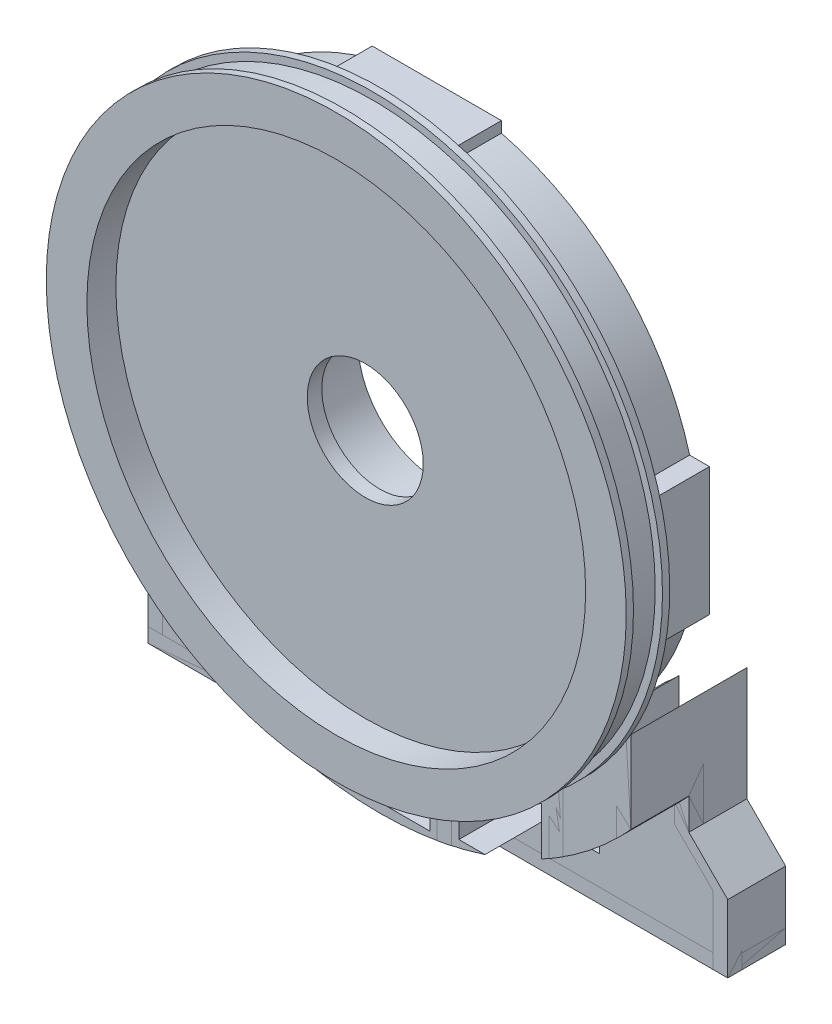
from build123d import *
from build123d.topology import SkipClean

# Parameters (mm, degrees)
SKETCH1_R                 = 200
BOSS_EXTRUDE1_DEPTH       = 5
SKETCH2_R                 = 195
BOSS_EXTRUDE2_DEPTH       = 10
SKETCH4_R                 = 180
SKETCH4_R_2               = 172
BOSS_EXTRUDE3_DEPTH       = 40
CUT_EXTRUDE1_DEPTH        = 286.657137142
CUT_EXTRUDE1_DEPTH_BACK   = 286.657137142
SKETCH6_R                 = 40
SKETCH7_R                 = 172
CUT_EXTRUDE2_DEPTH        = 20
BOSS_EXTRUDE12_DEPTH      = 40
CIRPATTERN7_COUNT         = 12
SKETCH5_R                 = 104.5
SKETCH5_R_2               = 96.5
BOSS_EXTRUDE14_DEPTH      = 40
SKETCH16_R                = 63
SKETCH16_R_2              = 55
BOSS_EXTRUDE15_DEPTH      = 40
CUT_EXTRUDE9_START        = -40
SKETCH18_R                = 55
CUT_EXTRUDE9_DEPTH        = 40
CUT_EXTRUDE13_DEPTH       = 40
BOSS_EXTRUDE18_START      = -40
SKETCH25_W                = 60.032294261
SKETCH25_H                = 45.012979572
BOSS_EXTRUDE18_DEPTH      = 40
SKETCH27_W                = 60.032294261
SKETCH27_H                = 45.012979572
SKETCH27_H_2              = 26.987020428
CUT_EXTRUDE15_DEPTH       = 40
CUT_EXTRUDE16_START       = -35
CUT_EXTRUDE16_DEPTH       = 35
BOSS_EXTRUDE19_START      = -44
SKETCH31_W                = 5.866847787
SKETCH31_H                = 9.437366397
SKETCH31_W_2              = 76.032294261
SKETCH31_W_3              = 7.195155409
BOSS_EXTRUDE19_DEPTH      = 44
BOSS_EXTRUDE20_DEPTH      = 80
BOSS_EXTRUDE21_DEPTH      = 80
BOSS_EXTRUDE21_2_DEPTH    = 80
BOSS_EXTRUDE26_DEPTH      = 50
CUT_EXTRUDE17_DEPTH       = 40
SKETCH41_W                = 400
SKETCH41_H                = 137.842811608
CUT_EXTRUDE18_DEPTH       = 452.7492864
BOSS_EXTRUDE29_DEPTH      = 40
BOSS_EXTRUDE29_DEPTH_BACK = 10
SKETCH42_W                = 400
SKETCH42_H                = 10
BOSS_EXTRUDE31_DEPTH      = 40
CUT_EXTRUDE19_DEPTH       = 332.517722
CUT_EXTRUDE20_DEPTH       = 10


with BuildPart() as part:
    # Sketch1 → Boss-Extrude1 (new body)
    with BuildSketch(Plane.XY):
        Circle(SKETCH1_R)
    boss_extrude1 = extrude(amount=BOSS_EXTRUDE1_DEPTH)

    # Sketch2 → Boss-Extrude2 (add)
    with BuildSketch(Plane.XY.offset(5)):
        Circle(SKETCH2_R)
    boss_extrude2 = extrude(amount=BOSS_EXTRUDE2_DEPTH)

    # Mirror2: Boss-Extrude2 across plane
    add(boss_extrude2.mirror(Plane.XY.offset(15)))

    # Mirror3: Boss-Extrude1 across plane
    add(boss_extrude1.mirror(Plane.XY.offset(15)))

    # Sketch4 → Boss-Extrude3 (add)
    with BuildSketch(Plane.XY):
        Circle(SKETCH4_R)
        Circle(SKETCH4_R_2, mode=Mode.SUBTRACT)
    extrude(amount=-BOSS_EXTRUDE3_DEPTH)

    # Sketch6 → Cut-Extrude1 (cut, two sides: drawn at the far end of the back side and taken through both)
    with BuildSketch(Plane(origin=(0, 0, 0), x_dir=(-1, 0, 0), z_dir=(0, 0, -1)).offset(-CUT_EXTRUDE1_DEPTH_BACK)):
        Circle(SKETCH6_R)
    extrude(amount=CUT_EXTRUDE1_DEPTH + CUT_EXTRUDE1_DEPTH_BACK, mode=Mode.SUBTRACT)

    # Sketch7 → Cut-Extrude2 (cut)
    with BuildSketch(Plane.XY.offset(30)):
        Circle(SKETCH7_R)
    extrude(amount=-CUT_EXTRUDE2_DEPTH, mode=Mode.SUBTRACT)

    # Sketch11 → Boss-Extrude12 (add)
    with BuildSketch(Plane(origin=(0, 0, 0), x_dir=(-1, 0, 0), z_dir=(0, 0, -1))):
        Polygon((7.035778174, -38.94988518), (13.739038842, -37.032866306), (48.739799741, -168.484156352), (41.858359492, -170.324504337), align=None)
    boss_extrude12 = extrude(amount=BOSS_EXTRUDE12_DEPTH)

    # CirPattern7: Boss-Extrude12 ×12 about axis
    cirpattern7_axis = Axis((0, 0, 0), (0, 0, 1))
    for i in range(1, CIRPATTERN7_COUNT):
        add(boss_extrude12.rotate(cirpattern7_axis, i * 360 / CIRPATTERN7_COUNT))

    # Sketch5 → Boss-Extrude14 (add)
    with BuildSketch(Plane(origin=(0, 0, 0), x_dir=(-1, 0, 0), z_dir=(0, 0, -1))):
        Circle(SKETCH5_R)
        Circle(SKETCH5_R_2, mode=Mode.SUBTRACT)
    extrude(amount=BOSS_EXTRUDE14_DEPTH)

    # Sketch16 → Boss-Extrude15 (add)
    with BuildSketch(Plane(origin=(0, 0, 0), x_dir=(-1, 0, 0), z_dir=(0, 0, -1))):
        Circle(SKETCH16_R)
        Circle(SKETCH16_R_2, mode=Mode.SUBTRACT)
    extrude(amount=BOSS_EXTRUDE15_DEPTH)

    # Sketch18 → Cut-Extrude9 (cut)
    with BuildSketch(Plane(origin=(0, 0, -40), x_dir=(-1, 0, 0), z_dir=(0, 0, -1)).offset(CUT_EXTRUDE9_START)):
        Circle(SKETCH18_R)
    extrude(amount=CUT_EXTRUDE9_DEPTH, mode=Mode.SUBTRACT)

    # Sketch20 → Cut-Extrude13 (cut)
    with SkipClean():  # the faces are left unmerged after this step: merging them gives an invalid solid
        with BuildSketch(Plane(origin=(0, 0, 0), x_dir=(-1, 0, 0), z_dir=(0, 0, -1))):
            with BuildLine():
                Line((-76.383232436, 71.315158295), (-124.056442132, 119.138571275))
                ThreePointArc((-124.056442132, 119.138571275), (0.082293709, 171.999980313), (124.170389449, 119.019806688))
                Line((124.170389449, 119.019806688), (76.298786502, 71.405498236))
                ThreePointArc((76.298786502, 71.405498236), (-0.061831263, 104.499981708), (-76.383232436, 71.315158295))
            make_face()
            with BuildLine():
                Line((-70.731344821, 65.645463361), (-47.053181493, 41.892697591))
                ThreePointArc((-47.053181493, 41.892697591), (-0.150655715, 62.999819864), (46.85228282, 42.117260055))
                Line((46.85228282, 42.117260055), (70.623866336, 65.761078943))
                ThreePointArc((70.623866336, 65.761078943), (-0.078928112, 96.499967722), (-70.731344821, 65.645463361))
            make_face()
        extrude(amount=CUT_EXTRUDE13_DEPTH, mode=Mode.SUBTRACT)

    # Sketch25 → Boss-Extrude18 (add)
    with SkipClean():  # the faces are left unmerged after this step: merging them gives an invalid solid
        with BuildSketch(Plane(origin=(0, 0, -40), x_dir=(-1, 0, 0), z_dir=(0, 0, -1)).offset(BOSS_EXTRUDE18_START)):
            with BuildLine():
                Line((38, 39.761790704), (38, 175.943172644))
                ThreePointArc((38, 175.943172644), (34.008709182, 176.758048472), (30, 177.482393493))
                Line((30, 177.482393493), (30, 130))
                Line((30, 130), (-30.032294261, 130))
                Line((-30.032294261, 130), (-30.032294261, 177.476931744))
                ThreePointArc((-30.032294261, 177.476931744), (-34.041012328, 176.751830202), (-38.032294261, 175.936194665))
                Line((-38.032294261, 175.936194665), (-38.032294261, 39.730902246))
                ThreePointArc((-38.032294261, 39.730902246), (-34.179881599, 43.089856044), (-30.032294261, 46.07668935))
                Line((-30.032294261, 46.07668935), (-30.032294261, 66.987020428))
                Line((-30.032294261, 66.987020428), (30, 66.987020428))
                Line((30, 66.987020428), (30, 46.097722286))
                ThreePointArc((30, 46.097722286), (34.147269397, 43.115704711), (38, 39.761790704))
            make_face()
            with Locations((-0.01614713, 99.493510214)):
                Rectangle(SKETCH25_W, SKETCH25_H, mode=Mode.SUBTRACT)
        extrude(amount=BOSS_EXTRUDE18_DEPTH)

    # Sketch27 → Cut-Extrude15 (cut)
    with SkipClean():  # the faces are left unmerged after this step: merging them gives an invalid solid
        with BuildSketch(Plane(origin=(0, 0, 0), x_dir=(-1, 0, 0), z_dir=(0, 0, -1))):
            with Locations((-0.01614713, 99.493510214)):
                Rectangle(SKETCH27_W, SKETCH27_H)
            with Locations((-0.01614713, 53.493510214)):
                Rectangle(SKETCH27_W, SKETCH27_H_2)
        extrude(amount=CUT_EXTRUDE15_DEPTH, mode=Mode.SUBTRACT)

    # Sketch30 → Cut-Extrude16 (cut)
    with SkipClean():  # the faces are left unmerged after this step: merging them gives an invalid solid
        with BuildSketch(Plane(origin=(0, 0, -50), x_dir=(-1, 0, 0), z_dir=(0, 0, -1)).offset(CUT_EXTRUDE16_START)):
            with BuildLine():
                Line((-38.032294261, 130), (38, 130))
                Line((38, 130), (38, 167.749813711))
                ThreePointArc((38, 167.749813711), (-0.016556603, 171.999999203), (-38.032294261, 167.742494894))
                Line((-38.032294261, 167.742494894), (-38.032294261, 130))
            make_face()
        extrude(amount=CUT_EXTRUDE16_DEPTH, mode=Mode.SUBTRACT)

    # Sketch31 → Boss-Extrude19 (add)
    with SkipClean():  # the faces are left unmerged after this step: merging them gives an invalid solid
        with BuildSketch(Plane(origin=(0, 0, -40), x_dir=(-1, 0, 0), z_dir=(0, 0, -1)).offset(BOSS_EXTRUDE19_START)):
            with BuildLine():
                ThreePointArc((-43.899142048, 166.303533719), (-40.972035783, 167.048772171), (-38.032294261, 167.742494894))
                Line((-38.032294261, 167.742494894), (-38.032294261, 172.64311533))
                Line((-38.032294261, 172.64311533), (-43.899142048, 172.64311533))
                Line((-43.899142048, 172.64311533), (-43.899142048, 166.303533719))
            make_face()
            with Locations((-40.965718155, 177.361798529)):
                Rectangle(SKETCH31_W, SKETCH31_H)
            with Locations((-0.016147131, 177.361798529)):
                Rectangle(SKETCH31_W_2, SKETCH31_H)
            with BuildLine():
                Line((-38.032294261, 172.64311533), (-38.032294261, 167.742494894))
                ThreePointArc((-38.032294261, 167.742494894), (-0.016556603, 171.999999203), (38, 167.749813711))
                Line((38, 167.749813711), (38, 172.64311533))
                Line((38, 172.64311533), (-38.032294261, 172.64311533))
            make_face()
            with BuildLine():
                Line((38, 172.64311533), (38, 167.749813711))
                ThreePointArc((38, 167.749813711), (41.607245787, 166.891692717), (45.195155409, 165.956012026))
                Line((45.195155409, 165.956012026), (45.195155409, 172.64311533))
                Line((45.195155409, 172.64311533), (38, 172.64311533))
            make_face()
            with Locations((41.597577704, 177.361798529)):
                Rectangle(SKETCH31_W_3, SKETCH31_H)
        extrude(amount=BOSS_EXTRUDE19_DEPTH)

    # Sketch32 → Boss-Extrude20 (add)
    with SkipClean():  # the faces are left unmerged after this step: merging them gives an invalid solid
        with BuildSketch(Plane.XY):
            with BuildLine():
                Line((125.869176934, -389.842811608), (126.470649272, -154.528527603))
                ThreePointArc((126.470649272, -154.528527603), (121.628078628, -158.368246375), (116.66900432, -162.056269245))
                Line((116.66900432, -162.056269245), (116.086773179, -389.842811608))
                Line((116.086773179, -389.842811608), (125.869176934, -389.842811608))
            make_face()
            with BuildLine():
                Line((126.470649272, -154.528527603), (126.538416981, -128.015737423))
                ThreePointArc((126.538416981, -128.015737423), (121.718930634, -132.606568183), (116.733008017, -137.016075113))
                Line((116.733008017, -137.016075113), (116.66900432, -162.056269245))
                ThreePointArc((116.66900432, -162.056269245), (121.628078628, -158.368246375), (126.470649272, -154.528527603))
            make_face()
            with BuildLine():
                Line((49.586808273, -193.429675634), (49.586808273, -173.035107551))
                ThreePointArc((49.586808273, -173.035107551), (44.605146714, -174.385724435), (39.586808273, -175.592951484))
                Line((39.586808273, -175.592951484), (39.586808273, -195.721167944))
                ThreePointArc((39.586808273, -195.721167944), (44.601526949, -194.639653628), (49.586808273, -193.429675634))
            make_face()
            with BuildLine():
                Line((49.586808273, -389.842811608), (49.586808273, -193.429675634))
                ThreePointArc((49.586808273, -193.429675634), (44.601526949, -194.639653628), (39.586808273, -195.721167944))
                Line((39.586808273, -195.721167944), (39.586808273, -389.842811608))
                Line((39.586808273, -389.842811608), (49.586808273, -389.842811608))
            make_face()
            with BuildLine():
                ThreePointArc((-39.427863087, -175.628709534), (-44.446127643, -174.426321802), (-49.427863087, -173.080577624))
                Line((-49.427863087, -173.080577624), (-49.427863087, -193.470352564))
                ThreePointArc((-49.427863087, -193.470352564), (-44.442523811, -194.676020731), (-39.427863087, -195.753249227))
                Line((-39.427863087, -195.753249227), (-39.427863087, -175.628709534))
            make_face()
            with BuildLine():
                ThreePointArc((-39.427863087, -195.753249227), (-44.442523811, -194.676020731), (-49.427863087, -193.470352564))
                Line((-49.427863087, -193.470352564), (-49.427863087, -389.842811608))
                Line((-49.427863087, -389.842811608), (-39.427863087, -389.842811608))
                Line((-39.427863087, -389.842811608), (-39.427863087, -195.753249227))
            make_face()
            with BuildLine():
                ThreePointArc((-116.53812441, -137.181870373), (-121.624499416, -132.693184233), (-126.53812441, -128.016026617))
                Line((-126.53812441, -128.016026617), (-126.53812441, -154.473279376))
                ThreePointArc((-126.53812441, -154.473279376), (-121.598726479, -158.390784736), (-116.53812441, -162.150413288))
                Line((-116.53812441, -162.150413288), (-116.53812441, -137.181870373))
            make_face()
            with BuildLine():
                ThreePointArc((-116.53812441, -162.150413288), (-121.598726479, -158.390784736), (-126.53812441, -154.473279376))
                Line((-126.53812441, -154.473279376), (-126.53812441, -389.842811608))
                Line((-126.53812441, -389.842811608), (-116.53812441, -389.842811608))
                Line((-116.53812441, -389.842811608), (-116.53812441, -162.150413288))
            make_face()
        extrude(amount=-BOSS_EXTRUDE20_DEPTH)


with BuildPart() as body_2:
    # Sketch33 → Boss-Extrude21 (new body)
    with BuildSketch(Plane(origin=(0, 0, 0), x_dir=(-1, 0, 0), z_dir=(0, 0, -1))):
        with BuildLine():
            ThreePointArc((-163.205080757, -115.603207633), (-168.385908599, -107.91749527), (-173.205080757, -100))
            Line((-173.205080757, -100), (-173.205080757, -178.365564659))
            Line((-173.205080757, -178.365564659), (-200, -205.160483902))
            Line((-200, -205.160483902), (-200, -389.842811608))
            Line((-200, -389.842811608), (-190, -389.842811608))
            Line((-190, -389.842811608), (-190, -205.160483902))
            Line((-190, -205.160483902), (-163.205080757, -178.365564659))
            Line((-163.205080757, -178.365564659), (-163.205080757, -115.603207633))
        make_face()
    extrude(amount=BOSS_EXTRUDE21_DEPTH)


with BuildPart() as body_3:
    # Sketch33 → Boss-Extrude21 2 (new body)
    with BuildSketch(Plane(origin=(0, 0, 0), x_dir=(-1, 0, 0), z_dir=(0, 0, -1))):
        with BuildLine():
            ThreePointArc((173.205080757, -100), (168.385908599, -107.91749527), (163.205080757, -115.603207633))
            Line((163.205080757, -115.603207633), (163.205080757, -178.648465684))
            Line((163.205080757, -178.648465684), (190, -205.443384928))
            Line((190, -205.443384928), (190, -389.842811608))
            Line((190, -389.842811608), (200, -389.842811608))
            Line((200, -389.842811608), (200, -205.443384928))
            Line((200, -205.443384928), (173.205080757, -178.648465684))
            Line((173.205080757, -178.648465684), (173.205080757, -100))
        make_face()
    extrude(amount=BOSS_EXTRUDE21_2_DEPTH)


with BuildPart() as body_4:
    # Sketch34 → Boss-Extrude26 (new body)
    with BuildSketch(Plane(origin=(0, 0, 0), x_dir=(-1, 0, 0), z_dir=(0, 0, -1))):
        with BuildLine():
            Line((-200, -205.160483902), (-200, -389.842811608))
            Line((-200, -389.842811608), (200, -389.842811608))
            Line((200, -389.842811608), (200, -205.443384928))
            Line((200, -205.443384928), (173.205080757, -178.648465684))
            Line((173.205080757, -178.648465684), (173.205080757, -100))
            ThreePointArc((173.205080757, -100), (0, -200), (-173.205080757, -100))
            Line((-173.205080757, -100), (-173.205080757, -178.365564659))
            Line((-173.205080757, -178.365564659), (-200, -205.160483902))
        make_face()
    extrude(amount=BOSS_EXTRUDE26_DEPTH)


with BuildPart() as cut_extrude17_tool:
    # Sketch39 → Cut-Extrude17 (new body)
    with SkipClean():  # the faces are left unmerged after this step: merging them gives an invalid solid
        with BuildSketch(Plane.XY.offset(10)):
            with BuildLine():
                Line((-233.56, 0), (-438.152276911, 0))
                ThreePointArc((-438.152276911, 0), (0, -438.152276911), (438.152276911, 0))
                Line((438.152276911, 0), (233.56, 0))
                ThreePointArc((233.56, 0), (0, -233.56), (-233.56, 0))
            make_face()
        extrude(amount=-CUT_EXTRUDE17_DEPTH)


with BuildPart() as part_1:
    with SkipClean():  # the faces are left unmerged after this step: merging them gives an invalid solid
        add(part.part)

        # Cut-Extrude17: cut by cut_extrude17_tool
        add(cut_extrude17_tool.part, mode=Mode.SUBTRACT)


with BuildPart() as body_2_1:
    with SkipClean():  # the faces are left unmerged after this step: merging them gives an invalid solid
        add(body_2.part)

        # Cut-Extrude17: cut by cut_extrude17_tool
        add(cut_extrude17_tool.part, mode=Mode.SUBTRACT)


with BuildPart() as body_3_1:
    with SkipClean():  # the faces are left unmerged after this step: merging them gives an invalid solid
        add(body_3.part)

        # Cut-Extrude17: cut by cut_extrude17_tool
        add(cut_extrude17_tool.part, mode=Mode.SUBTRACT)


with BuildPart() as body_4_1:
    with SkipClean():  # the faces are left unmerged after this step: merging them gives an invalid solid
        add(body_4.part)

        # Cut-Extrude17: cut by cut_extrude17_tool
        add(cut_extrude17_tool.part, mode=Mode.SUBTRACT)


with BuildPart() as cut_extrude18_tool:
    # Sketch41 → Cut-Extrude18 (new, through all)
    with SkipClean():  # the faces are left unmerged after this step: merging them gives an invalid solid
        with BuildSketch(Plane.XY.offset(30)):
            with Locations((0, -320.921405804)):
                Rectangle(SKETCH41_W, SKETCH41_H)
        extrude(amount=-CUT_EXTRUDE18_DEPTH)


with BuildPart() as part_2:
    with SkipClean():  # the faces are left unmerged after this step: merging them gives an invalid solid
        add(part_1.part)

        # Cut-Extrude18: cut by cut_extrude18_tool
        add(cut_extrude18_tool.part, mode=Mode.SUBTRACT)

    # Sketch43 → Boss-Extrude31 (add)
    with SkipClean():  # the faces are left unmerged after this step: merging them gives an invalid solid
        with BuildSketch(Plane(origin=(0, 0, 0), x_dir=(-1, 0, 0), z_dir=(0, 0, -1))):
            with BuildLine():
                Line((-187.401213635, 47.186602235), (-187.401213635, 2.404763167))
                Line((-187.401213635, 2.404763167), (-187.401213635, -41.258292441))
                Line((-187.401213635, -41.258292441), (-169.992225382, -41.258292441))
                ThreePointArc((-169.992225382, -41.258292441), (-175.61, 3.065283952), (-168.578066489, 47.186602235))
                Line((-168.578066489, 47.186602235), (-187.401213635, 47.186602235))
            make_face()
            with BuildLine():
                Line((191.292951171, -20.283337239), (185.998350383, 22.83772578))
                Line((185.998350383, 22.83772578), (180.514229929, 67.502302604))
                Line((180.514229929, 67.502302604), (163.235005634, 65.380680636))
                ThreePointArc((163.235005634, 65.380680636), (174.212591365, 22.072119964), (172.610108909, -22.577301823))
                Line((172.610108909, -22.577301823), (191.292951171, -20.283337239))
            make_face()
        extrude(amount=BOSS_EXTRUDE31_DEPTH)


with BuildPart() as body_2_2:
    with SkipClean():  # the faces are left unmerged after this step: merging them gives an invalid solid
        add(body_2_1.part)

        # Cut-Extrude18: cut by cut_extrude18_tool
        add(cut_extrude18_tool.part, mode=Mode.SUBTRACT)


with BuildPart() as body_3_2:
    with SkipClean():  # the faces are left unmerged after this step: merging them gives an invalid solid
        add(body_3_1.part)

        # Cut-Extrude18: cut by cut_extrude18_tool
        add(cut_extrude18_tool.part, mode=Mode.SUBTRACT)


with BuildPart() as body_4_2:
    with SkipClean():  # the faces are left unmerged after this step: merging them gives an invalid solid
        add(body_4_1.part)

        # Cut-Extrude18: cut by cut_extrude18_tool
        add(cut_extrude18_tool.part, mode=Mode.SUBTRACT)

    # Sketch45 → Cut-Extrude19 (cut, through all)
    with BuildSketch(Plane(origin=(0, 0, -50), x_dir=(-1, 0, 0), z_dir=(0, 0, -1))):
        with BuildLine():
            Line((34.427863087, -227), (34.427863087, -202.08840205))
            ThreePointArc((34.427863087, -202.08840205), (-0.080623006, -204.999984146), (-34.586808273, -202.061259754))
            Line((-34.586808273, -202.061259754), (-34.586808273, -227))
            Line((-34.586808273, -227), (34.427863087, -227))
        make_face()
        with BuildLine():
            Line((54.427863087, -197.642626272), (54.427863087, -222))
            Line((54.427863087, -222), (111.53812441, -222))
            Line((111.53812441, -222), (111.53812441, -172.000717449))
            ThreePointArc((111.53812441, -172.000717449), (83.967577811, -187.0145606), (54.427863087, -197.642626272))
        make_face()
        with BuildLine():
            ThreePointArc((-54.586808273, -197.598786339), (-84.030627785, -186.98623905), (-111.515769511, -172.015211974))
            Line((-111.515769511, -172.015211974), (-111.515769511, -222))
            Line((-111.515769511, -222), (-54.586808273, -222))
            Line((-54.586808273, -222), (-54.586808273, -197.598786339))
        make_face()
    extrude(amount=-CUT_EXTRUDE19_DEPTH, mode=Mode.SUBTRACT)


with BuildPart() as body_5:
    # Sketch42 → Boss-Extrude29 (new, two sides: drawn at the far end of the back side and taken through both)
    with BuildSketch(Plane(origin=(0, 0, -40), x_dir=(-1, 0, 0), z_dir=(0, 0, -1)).offset(-BOSS_EXTRUDE29_DEPTH_BACK)):
        with Locations((0, -247)):
            Rectangle(SKETCH42_W, SKETCH42_H)
    extrude(amount=BOSS_EXTRUDE29_DEPTH + BOSS_EXTRUDE29_DEPTH_BACK)


with BuildPart() as cut_extrude20_tool:
    # Sketch48 → Cut-Extrude20 (new body)
    with SkipClean():  # the faces are left unmerged after this step: merging them gives an invalid solid
        with BuildSketch(Plane.XY.offset(-30)):
            with BuildLine():
                Line((-200, -252), (200, -252))
                Line((200, -252), (200, -155.878801719))
                Line((200, -155.878801719), (173.931230016, -155.878801719))
                ThreePointArc((173.931230016, -155.878801719), (0, -233.56), (-173.931230016, -155.878801719))
                Line((-173.931230016, -155.878801719), (-200, -155.878801719))
                Line((-200, -155.878801719), (-200, -252))
            make_face()
        extrude(amount=-CUT_EXTRUDE20_DEPTH)


with BuildPart() as part_3:
    with SkipClean():  # the faces are left unmerged after this step: merging them gives an invalid solid
        add(part_2.part)

        # Cut-Extrude20: cut by cut_extrude20_tool
        add(cut_extrude20_tool.part, mode=Mode.SUBTRACT)


with BuildPart() as body_2_3:
    with SkipClean():  # the faces are left unmerged after this step: merging them gives an invalid solid
        add(body_2_2.part)

        # Cut-Extrude20: cut by cut_extrude20_tool
        add(cut_extrude20_tool.part, mode=Mode.SUBTRACT)


with BuildPart() as body_3_3:
    with SkipClean():  # the faces are left unmerged after this step: merging them gives an invalid solid
        add(body_3_2.part)

        # Cut-Extrude20: cut by cut_extrude20_tool
        add(cut_extrude20_tool.part, mode=Mode.SUBTRACT)


with BuildPart() as body_4_3:
    with SkipClean():  # the faces are left unmerged after this step: merging them gives an invalid solid
        add(body_4_2.part)

        # Cut-Extrude20: cut by cut_extrude20_tool
        add(cut_extrude20_tool.part, mode=Mode.SUBTRACT)


with BuildPart() as body_5_1:
    with SkipClean():  # the faces are left unmerged after this step: merging them gives an invalid solid
        add(body_5.part)

        # Cut-Extrude20: cut by cut_extrude20_tool
        add(cut_extrude20_tool.part, mode=Mode.SUBTRACT)


solid = Compound([part_3.part, body_2_3.part, body_3_3.part, body_4_3.part, body_5_1.part])
